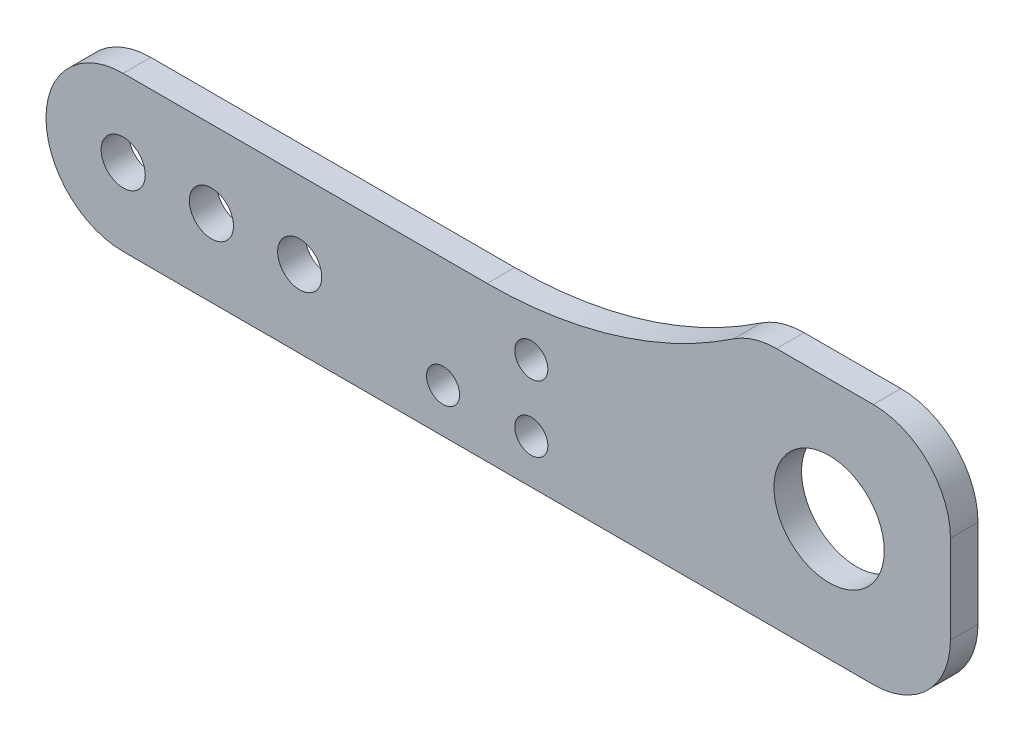
from build123d import *

# Parameters (mm, degrees)
BOSS_EXTRUDE1_DEPTH   = 2.5
SKETCH2_R             = 2
CUT_EXTRUDE1_DEPTH    = 2.5
SKETCH3_R             = 5
CUT_EXTRUDE2_DEPTH    = 2.5
F_3_0MM_DOWEL_HOLE2_D = 3


with BuildPart() as part:
    # Sketch1 → Boss-Extrude1 (new body)
    with BuildSketch(Plane.XY):
        with BuildLine():
            Line((0, 7), (33, 7))
            ThreePointArc((33, 7), (44.66919932, 8.739971416), (55.323194976, 13.808510638))
            ThreePointArc((55.323194976, 13.808510638), (57.187644216, 14.695505002), (59.229754097, 15))
            Line((59.229754097, 15), (68, 15))
            ThreePointArc((68, 15), (72.949747468, 12.949747468), (75, 8))
            Line((75, 8), (75, 0))
            ThreePointArc((75, 0), (72.949747468, -4.949747468), (68, -7))
            Line((68, -7), (0, -7))
            ThreePointArc((0, -7), (-7, 0), (0, 7))
        make_face()
    extrude(amount=BOSS_EXTRUDE1_DEPTH)

    # Sketch2 → Cut-Extrude1 (cut)
    with BuildSketch(Plane.XY.offset(2.5)):
        Circle(SKETCH2_R)
        with Locations((8, 0)):
            Circle(SKETCH2_R)
        with Locations((16, 0)):
            Circle(SKETCH2_R)
    extrude(amount=-CUT_EXTRUDE1_DEPTH, mode=Mode.SUBTRACT)

    # Sketch3 → Cut-Extrude2 (cut)
    with BuildSketch(Plane.XY.offset(2.5)):
        with Locations((64, 4)):
            Circle(SKETCH3_R)
    extrude(amount=-CUT_EXTRUDE2_DEPTH, mode=Mode.SUBTRACT)

    # Ø3.0mm Dowel Hole2 (through all)
    with Locations(Plane.XY.offset(2.5)):
        with Locations((29, -3), (37, -3), (37, 3)):
            Hole(F_3_0MM_DOWEL_HOLE2_D / 2)


solid = part.part
